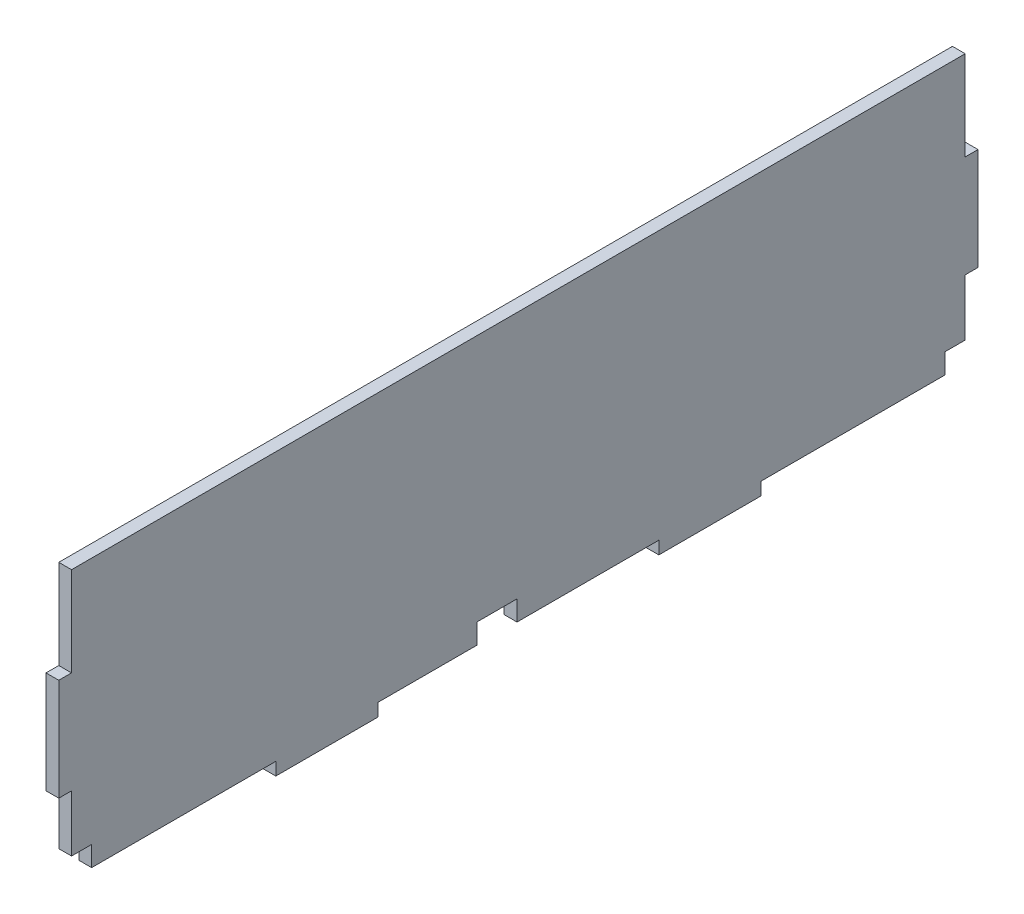
from build123d import *

# Parameters (mm, degrees)
BOSS_EXTRUDE1_DEPTH = 3.175
SKETCH2_W           = 222.25
SKETCH2_H           = 3.175
CUT_EXTRUDE1_DEPTH  = 4.175
SKETCH3_W           = 5
SKETCH3_H           = 5
SKETCH3_W_2         = 10
CUT_EXTRUDE2_DEPTH  = 10


with BuildPart() as part:
    # Sketch1 → Boss-Extrude1 (new body)
    with BuildSketch(Plane(origin=(0, 0, 0), x_dir=(0, 0, -1), z_dir=(1, 0, 0))):
        Polygon((-105.784096482, 33.834012461), (-105.784096482, 8.434012461), (-108.959096482, 8.434012461), (-108.959096482, -16.965987539), (-105.784096482, -16.965987539), (-105.784096482, -36.015987539), (-54.984096482, -36.015987539), (-54.984096482, -39.190987539), (-29.584096482, -39.190987539), (-29.584096482, -36.015987539), (40.265903518, -36.015987539), (40.265903518, -39.190987539), (65.665903518, -39.190987539), (65.665903518, -36.015987539), (116.465903518, -36.015987539), (116.465903518, -16.965987539), (119.640903518, -16.965987539), (119.640903518, 8.434012461), (116.465903518, 8.434012461), (116.465903518, 33.834012461), align=None)
    extrude(amount=BOSS_EXTRUDE1_DEPTH)

    # Sketch2 → Cut-Extrude1 (cut, through all)
    with BuildSketch(Plane(origin=(3.175, 0, 0), x_dir=(0, 0, -1), z_dir=(1, 0, 0))):
        with Locations((5.340903518, 32.246512461)):
            Rectangle(SKETCH2_W, SKETCH2_H)
    extrude(amount=-CUT_EXTRUDE1_DEPTH, mode=Mode.SUBTRACT)

    # Sketch3 → Cut-Extrude2 (cut)
    with BuildSketch(Plane(origin=(3.175, 0, 0), x_dir=(0, 0, -1), z_dir=(1, 0, 0))):
        with Locations((-103.284096482, -33.515987539)):
            Rectangle(SKETCH3_W, SKETCH3_H)
        with Locations((113.965903518, -33.515987539)):
            Rectangle(SKETCH3_W, SKETCH3_H)
        with Locations((0, -33.515987539)):
            Rectangle(SKETCH3_W_2, SKETCH3_H)
    extrude(amount=-CUT_EXTRUDE2_DEPTH, mode=Mode.SUBTRACT)


solid = part.part
